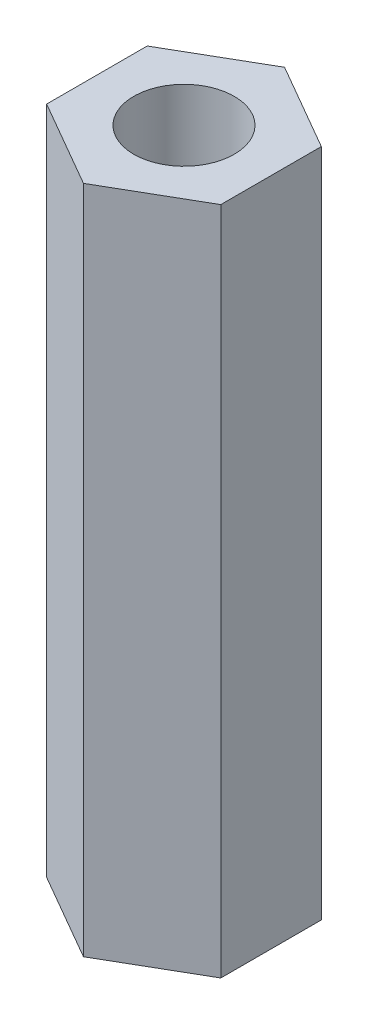
from build123d import *

# Parameters (mm, degrees)
SKETCH1_R           = 1.5
BOSS_EXTRUDE2_DEPTH = 20


with BuildPart() as part:
    # Sketch1 → Boss-Extrude2 (new body)
    with BuildSketch(Plane(origin=(0, 0, 0), x_dir=(1, 0, 0), z_dir=(0, 1, 0))):
        Polygon((0, 3.0022214), (-2.6, 1.5011107), (-2.6, -1.5011107), (0, -3.0022214), (2.6, -1.5011107), (2.6, 1.5011107), align=None)
        Circle(SKETCH1_R, mode=Mode.SUBTRACT)
    extrude(amount=BOSS_EXTRUDE2_DEPTH)


solid = part.part
